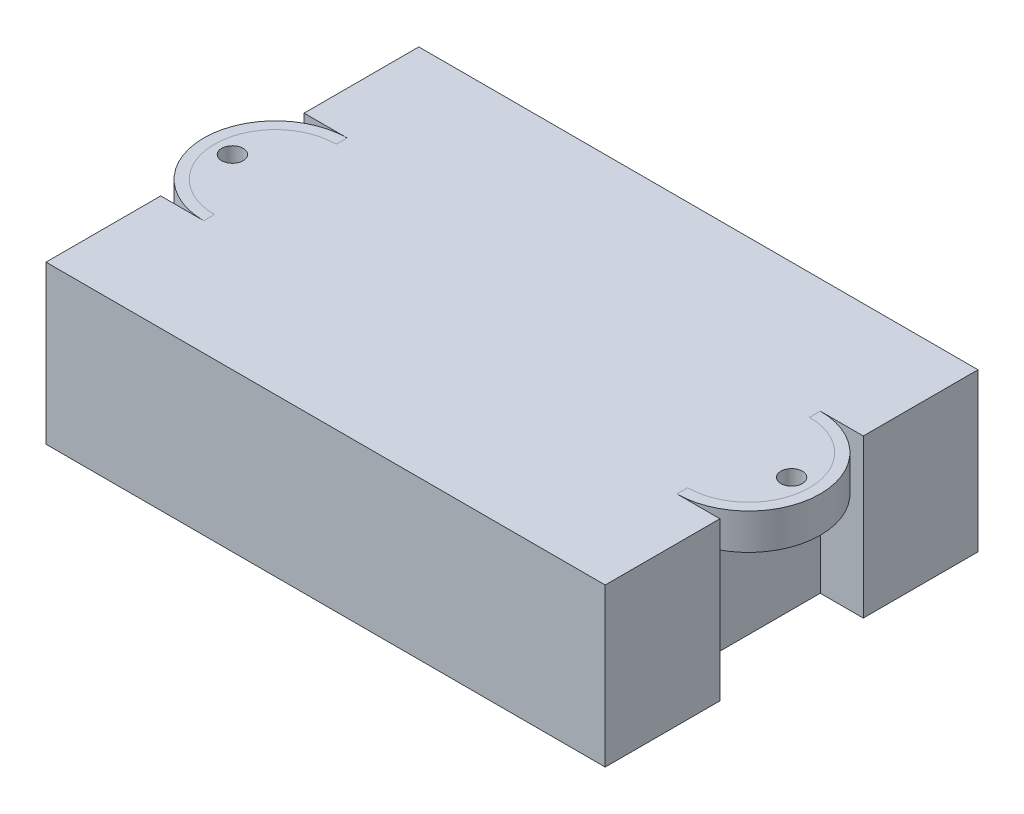
from build123d import *

# Parameters (mm, degrees)
SCHIZZO1_W                     = 78
SCHIZZO1_H                     = 52
ESTRUSIONE_ESTRUSIONE1_DEPTH   = 22
SCHIZZO3_W                     = 6
SCHIZZO3_H                     = 20
TAGLIO_ESTRUSIONE1_DEPTH       = 52.778373864
SCHIZZO4_R                     = 1.5
ESTRUSIONE_ESTRUSIONE2_DEPTH   = 4
ESTRUSIONE_ESTRUSIONE3_DEPTH   = 5
ESTRUSIONE_ESTRUSIONE3_2_DEPTH = 5


with BuildPart() as part:
    # Schizzo1 → Estrusione-Estrusione1 (new body)
    with BuildSketch(Plane(origin=(0, 0, 0), x_dir=(1, 0, 0), z_dir=(0, 1, 0))):
        Rectangle(SCHIZZO1_W, SCHIZZO1_H)
    extrude(amount=ESTRUSIONE_ESTRUSIONE1_DEPTH)

    # Schizzo3 → Taglio-Estrusione1 (cut, through all)
    with BuildSketch(Plane(origin=(0, 22, 0), x_dir=(1, 0, 0), z_dir=(0, 1, 0))):
        with Locations((-36, 0)):
            Rectangle(SCHIZZO3_W, SCHIZZO3_H)
        with Locations((36, 0)):
            Rectangle(SCHIZZO3_W, SCHIZZO3_H)
    extrude(amount=-TAGLIO_ESTRUSIONE1_DEPTH, mode=Mode.SUBTRACT)

    # Schizzo4 → Estrusione-Estrusione2 (add)
    # profile 1 of 2: a face of its own
    with BuildSketch(Plane(origin=(0, 22, 0), x_dir=(1, 0, 0), z_dir=(0, 1, 0))):
        with BuildLine():
            Line((-33, -8.5), (-33, 8.5))
            ThreePointArc((-33, 8.5), (-41.5, 0), (-33, -8.5))
        make_face()
        with Locations((-39, 0)):
            Circle(SCHIZZO4_R, mode=Mode.SUBTRACT)
    # profile 2 of 2: a face of its own
    with BuildSketch(Plane(origin=(0, 22, 0), x_dir=(1, 0, 0), z_dir=(0, 1, 0))):
        with BuildLine():
            ThreePointArc((33, -8.5), (41.5, 0), (33, 8.5))
            Line((33, 8.5), (33, -8.5))
        make_face()
        with Locations((39, 0)):
            Circle(SCHIZZO4_R, mode=Mode.SUBTRACT)
    extrude(amount=-ESTRUSIONE_ESTRUSIONE2_DEPTH)


with BuildPart() as body_2:
    # Schizzo4_3 → Estrusione-Estrusione3 (new body)
    with BuildSketch(Plane(origin=(0, 22, 0), x_dir=(1, 0, 0), z_dir=(0, 1, 0))):
        with BuildLine():
            Line((-33, 8.5), (-33, 10))
            ThreePointArc((-33, 10), (-43, 0), (-33, -10))
            Line((-33, -10), (-33, -8.5))
            ThreePointArc((-33, -8.5), (-41.5, 0), (-33, 8.5))
        make_face()
    extrude(amount=-ESTRUSIONE_ESTRUSIONE3_DEPTH)


with BuildPart() as body_3:
    # Schizzo4_3 → Estrusione-Estrusione3 2 (new body)
    with BuildSketch(Plane(origin=(0, 22, 0), x_dir=(1, 0, 0), z_dir=(0, 1, 0))):
        with BuildLine():
            Line((33, 10), (33, 8.5))
            ThreePointArc((33, 8.5), (41.5, 0), (33, -8.5))
            Line((33, -8.5), (33, -10))
            ThreePointArc((33, -10), (43, 0), (33, 10))
        make_face()
    extrude(amount=-ESTRUSIONE_ESTRUSIONE3_2_DEPTH)


solid = Compound([part.part, body_2.part, body_3.part])
